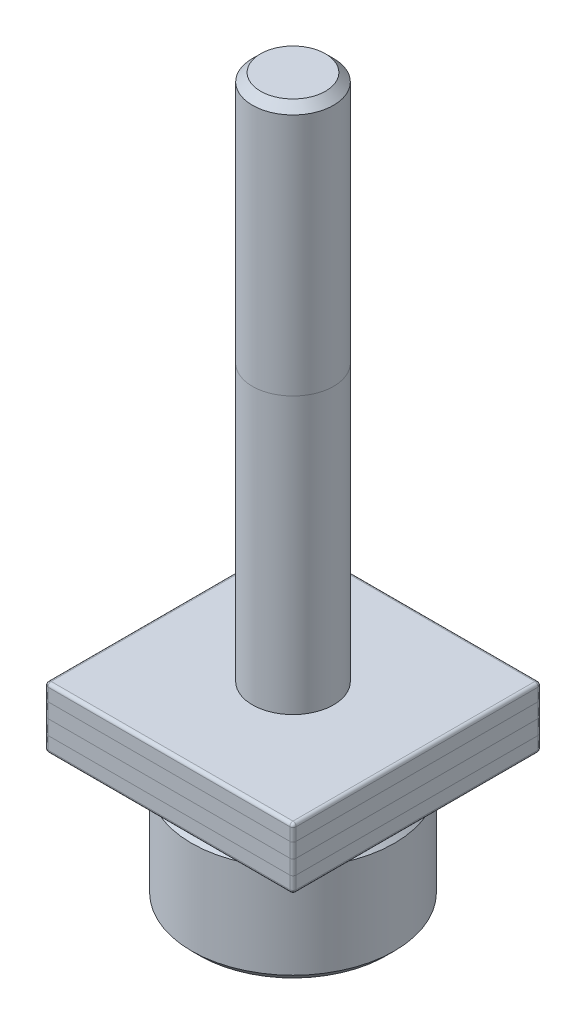
from build123d import *

# Parameters (mm, degrees)
SKETCH1_W          = 19.431
SKETCH1_H          = 19.431
EXTRUDE1_DEPTH     = 4.7752
SKETCH2_R          = 3.175
EXTRUDE2_DEPTH     = 41.275
SKETCH3_R          = 7.9375
EXTRUDE3_DEPTH     = 10.16
CHAMFER1_SIZE      = 0.635
CHAMFER2_SIZE      = 0.635
CUT_EXTRUDE1_DEPTH = 4.318
FILLET1_R          = 0.254


with BuildPart() as part:
    # Sketch1 → Extrude1 (new body)
    with BuildSketch(Plane(origin=(0, 0, 0), x_dir=(1, 0, 0), z_dir=(0, 1, 0))):
        Rectangle(SKETCH1_W, SKETCH1_H)
    extrude(amount=EXTRUDE1_DEPTH)

    # Sketch2 → Extrude2 (add)
    with BuildSketch(Plane(origin=(0, 4.7752, 0), x_dir=(-1, 0, 0), z_dir=(0, 1, 0))):
        with Locations(Location((0, 0, 0), (0, 0, 270))):  # turned: the seam where the file's is
            Circle(SKETCH2_R)
    extrude(amount=EXTRUDE2_DEPTH)

    # Sketch3 → Extrude3 (add)
    with BuildSketch(Plane.XZ):
        with Locations(Location((0, 0, 0), (0, 0, 270))):  # turned: the seam where the file's is
            Circle(SKETCH3_R)
    extrude(amount=EXTRUDE3_DEPTH)

    # Chamfer1
    chamfer1_edges = [part.edges().sort_by_distance(p)[0] for p in [
        (0, 46.0502, 3.175),
    ]]
    chamfer(chamfer1_edges, length=CHAMFER1_SIZE)

    # Sketch4 → Cut-Revolve1 (revolve, cut)
    with BuildSketch(Plane.XY, mode=Mode.PRIVATE) as cut_revolve1_sk:
        Polygon((-7.9375, 0), (-6.985, 0), (-6.985, -1.27), (-7.9375, -2.2225), align=None)
    revolve(cut_revolve1_sk.sketch.rotate(Axis((0, 0, 0), (0, -1, 0)), 270), axis=Axis((0, 0, 0), (0, -1, 0)), mode=Mode.SUBTRACT)  # turned: the seam where the file's is

    # Chamfer2
    chamfer2_edges = [part.edges().sort_by_distance(p)[0] for p in [
        (0, -10.16, 7.9375),
    ]]
    chamfer(chamfer2_edges, length=CHAMFER2_SIZE)

    # Sketch5 → Cut-Extrude1 (cut)
    with BuildSketch(Plane.XZ.offset(10.16)):
        Polygon((0, -2.786292399), (2.413, -1.3931462), (2.413, 1.3931462), (0, 2.786292399), (-2.413, 1.3931462), (-2.413, -1.3931462), align=None)
    extrude(amount=-CUT_EXTRUDE1_DEPTH, mode=Mode.SUBTRACT)

    # Fillet1
    fillet1_edges = [part.edges().sort_by_distance(p)[0] for p in [
        (9.7155, 4.7752, 0),
        (0, 4.7752, -9.7155),
        (-9.7155, 4.7752, 0),
        (0, 0, -9.7155),
        (9.7155, 0, 0),
        (0, 0, 9.7155),
        (-9.7155, 0, 0),
        (0, 4.7752, 9.7155),
        (-9.7155, 2.3876, -9.7155),
        (9.7155, 2.3876, -9.7155),
        (9.7155, 2.3876, 9.7155),
        (-9.7155, 2.3876, 9.7155),
    ]]
    fillet(fillet1_edges, radius=FILLET1_R)


solid = part.part
